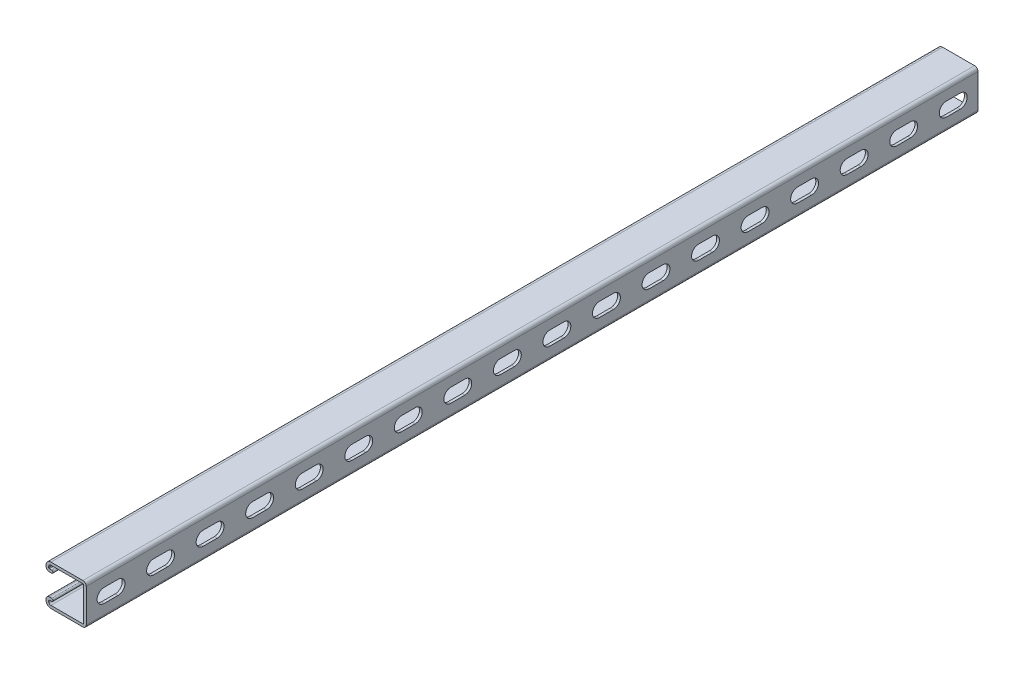
from build123d import *

# Parameters (mm, degrees)
BOSS_EXTRUDE1_DEPTH = 914.4
CUT_EXTRUDE1_DEPTH  = 2.794
LPATTERN1_COUNT     = 18
LPATTERN1_PITCH     = 50.8


with BuildPart() as part:
    # Sketch1 → Boss-Extrude1 (new body)
    with BuildSketch(Plane.XY):
        with BuildLine():
            Line((-36.22675, 20.6375), (-3.46075, 20.6375))
            ThreePointArc((-3.46075, 20.6375), (-1.013630207, 19.623869793), (0, 17.17675))
            Line((0, 17.17675), (0, -17.17675))
            ThreePointArc((0, -17.17675), (-1.013630207, -19.623869793), (-3.46075, -20.6375))
            Line((-3.46075, -20.6375), (-36.22675, -20.6375))
            ThreePointArc((-36.22675, -20.6375), (-39.796401808, -19.158901808), (-41.275, -15.58925))
            Line((-41.275, -15.58925), (-41.275, -14.57325))
            ThreePointArc((-41.275, -14.57325), (-40.261369793, -12.126130207), (-37.81425, -11.1125))
            Line((-37.81425, -11.1125), (-35.5346, -11.1125))
            ThreePointArc((-35.5346, -11.1125), (-34.1376, -12.5095), (-35.5346, -13.9065))
            Line((-35.5346, -13.9065), (-37.81425, -13.9065))
            ThreePointArc((-37.81425, -13.9065), (-38.285713446, -14.101786554), (-38.481, -14.57325))
            Line((-38.481, -14.57325), (-38.481, -15.58925))
            ThreePointArc((-38.481, -15.58925), (-37.820745461, -17.183245461), (-36.22675, -17.8435))
            Line((-36.22675, -17.8435), (-3.46075, -17.8435))
            ThreePointArc((-3.46075, -17.8435), (-2.989286554, -17.648213446), (-2.794, -17.17675))
            Line((-2.794, -17.17675), (-2.794, 17.17675))
            ThreePointArc((-2.794, 17.17675), (-2.989286554, 17.648213446), (-3.46075, 17.8435))
            Line((-3.46075, 17.8435), (-36.22675, 17.8435))
            ThreePointArc((-36.22675, 17.8435), (-37.820745461, 17.183245461), (-38.481, 15.58925))
            Line((-38.481, 15.58925), (-38.481, 14.57325))
            ThreePointArc((-38.481, 14.57325), (-38.285713446, 14.101786554), (-37.81425, 13.9065))
            Line((-37.81425, 13.9065), (-35.5346, 13.9065))
            ThreePointArc((-35.5346, 13.9065), (-34.1376, 12.5095), (-35.5346, 11.1125))
            Line((-35.5346, 11.1125), (-37.81425, 11.1125))
            ThreePointArc((-37.81425, 11.1125), (-40.261369793, 12.126130207), (-41.275, 14.57325))
            Line((-41.275, 14.57325), (-41.275, 15.58925))
            ThreePointArc((-41.275, 15.58925), (-39.796401808, 19.158901808), (-36.22675, 20.6375))
        make_face()
    extrude(amount=-BOSS_EXTRUDE1_DEPTH)

    # Sketch2 → Cut-Extrude1 (cut)
    with BuildSketch(Plane(origin=(0, 0, 0), x_dir=(0, 0, -1), z_dir=(1, 0, 0))):
        with BuildLine():
            Line((18.25625, 7.14375), (32.54375, 7.14375))
            ThreePointArc((32.54375, 7.14375), (39.6875, 0), (32.54375, -7.14375))
            Line((32.54375, -7.14375), (18.25625, -7.14375))
            ThreePointArc((18.25625, -7.14375), (11.1125, 0), (18.25625, 7.14375))
        make_face()
    cut_extrude1 = extrude(amount=-CUT_EXTRUDE1_DEPTH, mode=Mode.SUBTRACT)

    # LPattern1: Cut-Extrude1 ×18
    with Locations(*[(0, 0, -i * LPATTERN1_PITCH) for i in range(1, LPATTERN1_COUNT)]):
        add(cut_extrude1, mode=Mode.SUBTRACT)


solid = part.part
